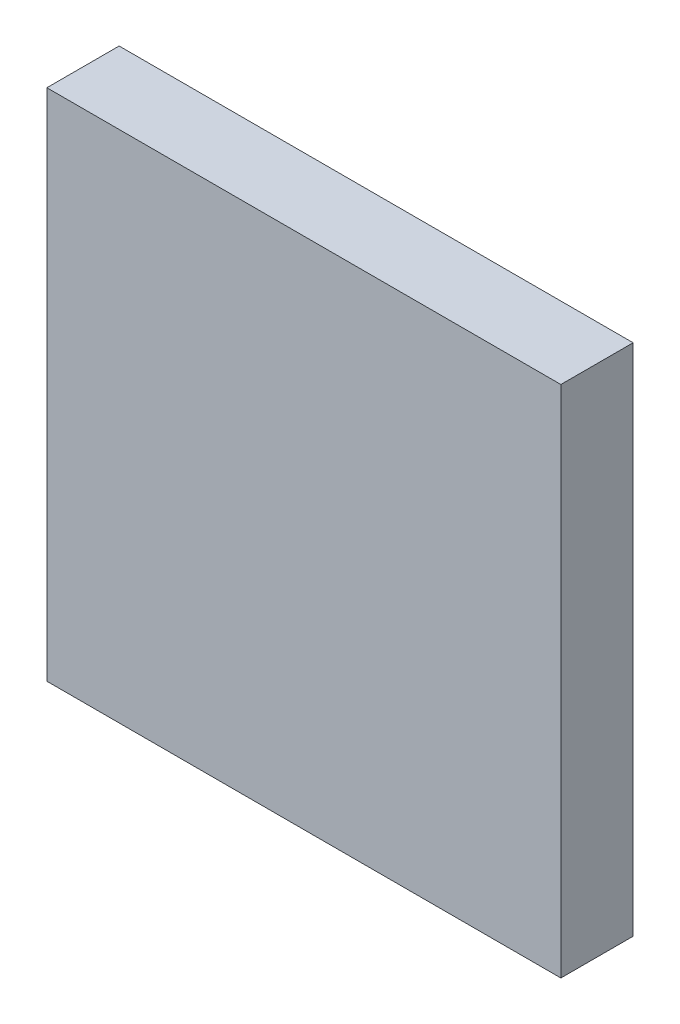
from build123d import *

# Parameters (mm, degrees)
SKETCH1_W               = 7.112
SKETCH1_H               = 7.112
COMPONENT_OUTLINE_DEPTH = 1


with BuildPart() as part:
    # Sketch1 → Component_Outline (new body)
    with BuildSketch(Plane.XY):
        Rectangle(SKETCH1_W, SKETCH1_H)
    extrude(amount=COMPONENT_OUTLINE_DEPTH)


solid = part.part
